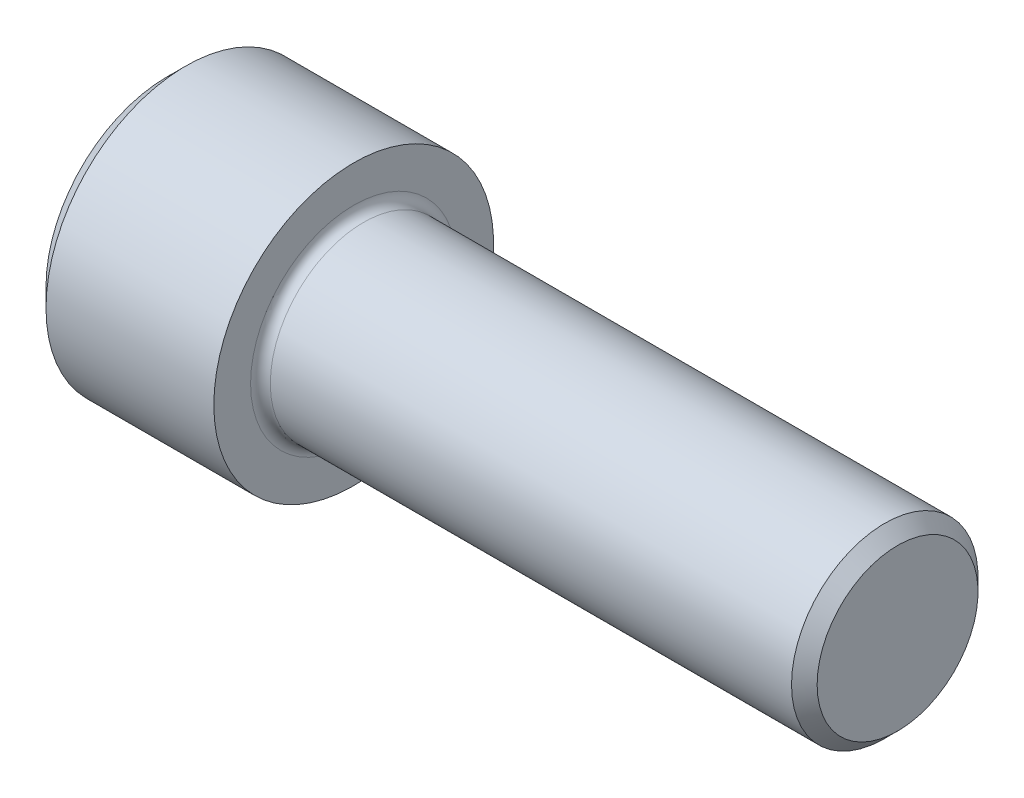
from build123d import *

# Parameters (mm, degrees)
FILLET1_R   = 1.27
HEX_2_DEPTH = 12


with BuildPart() as part:
    # BodySke → Base-Revolve (revolve)
    with BuildSketch(Plane.XY):
        Polygon((0, 0), (0, 15.6), (2.4, 18), (24, 18), (24, 12), (92.352, 12), (94, 10.352), (94, 0), align=None)
    revolve(axis=Axis((-31.75, 0, 0), (1, 0, 0)))

    # Fillet1
    fillet1_edges = [part.edges().sort_by_distance(p)[0] for p in [
        (24, -12, 0),
    ]]
    fillet(fillet1_edges, radius=FILLET1_R)

    # Sketch2 → Hex-PreBroach (revolve, cut)
    with BuildSketch(Plane.XY):
        Polygon((0, 9.5), (12, 9.5), (17.484827557, 0), (0, 0), align=None)
    revolve(axis=Axis((0, 0, 0), (1, 0, 0)), mode=Mode.SUBTRACT)

    # Sketch3 → Hex 2 (cut)
    with BuildSketch(Plane(origin=(0, 0, 0), x_dir=(0, 0.5, 0.866025404), z_dir=(-1, 0, 0))):
        Polygon((5.484827557, 9.5), (-5.484827557, 9.5), (-10.969655115, 0), (-5.484827557, -9.5), (5.484827557, -9.5), (10.969655115, 0), align=None)
    extrude(amount=-HEX_2_DEPTH, mode=Mode.SUBTRACT)


solid = part.part
